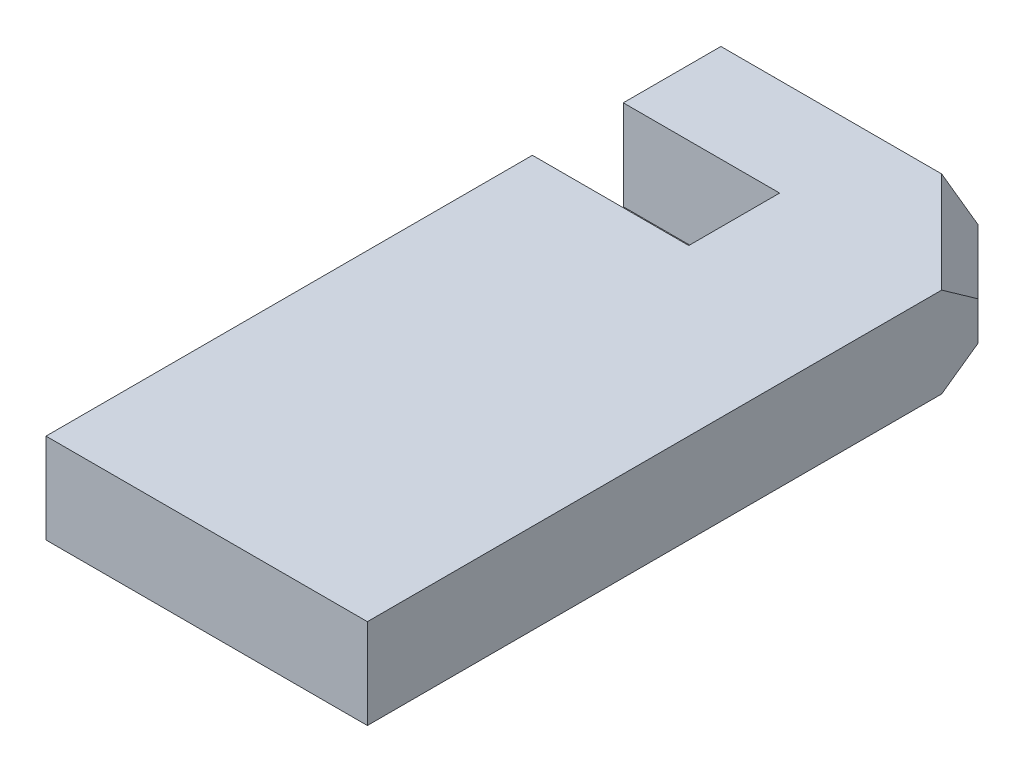
from build123d import *

# Parameters (mm, degrees)
EXTRUDE_1_DEPTH = 14
CHAMFER_1_SIZE  = 4


with BuildPart() as part:
    # 草图1 → 凸台-拉伸1 (new body)
    with BuildSketch(Plane(origin=(0, 0, 0), x_dir=(1, 0, 0), z_dir=(0, 1, 0))):
        Polygon((40, 105), (50, 95), (50, 0), (0, 0), (0, 75.675047551), (24.325372692, 75.675047551), (24.325372692, 89.813954871), (0, 89.813954871), (0, 105), align=None)
    extrude(amount=EXTRUDE_1_DEPTH)

    # 倒角1
    chamfer_1_edges = [part.edges().sort_by_distance(p)[0] for p in [
        (45, 0, -100),
        (45, 14, -100),
    ]]
    chamfer(chamfer_1_edges, length=CHAMFER_1_SIZE)


solid = part.part
